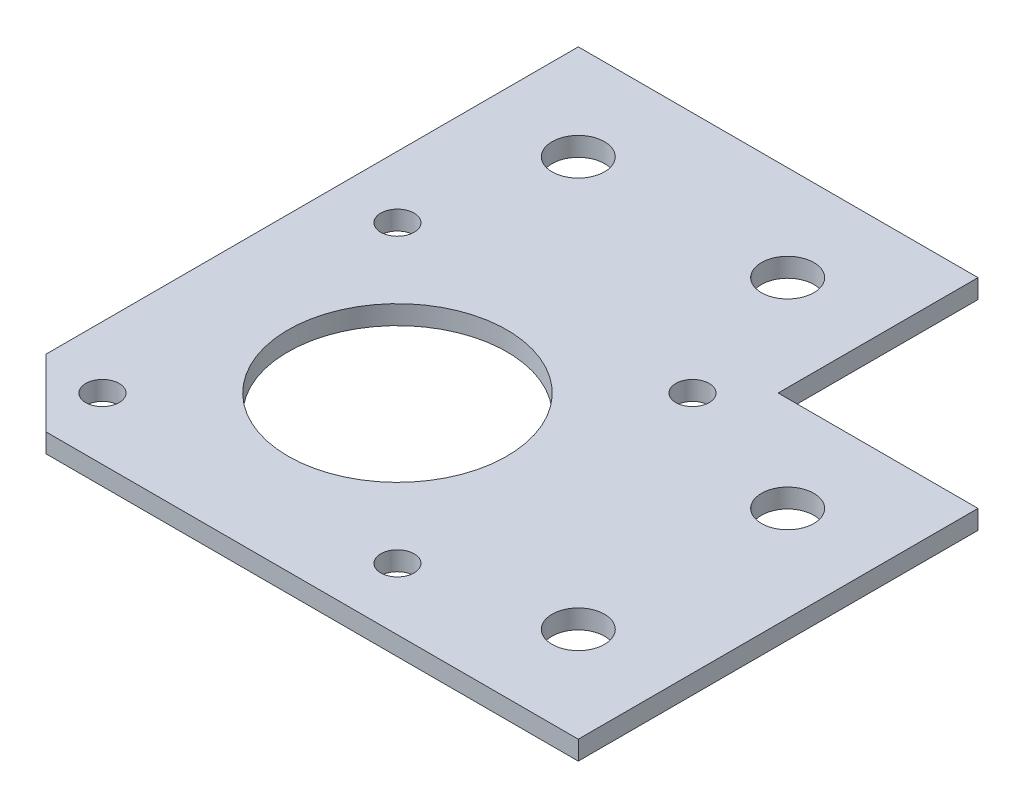
from build123d import *

# Parameters (mm, degrees)
EXTRUDE_1_DEPTH     = 2
SKETCH_3_R          = 2.75
SKETCH_3_R_2        = 1.75
SKETCH_3_R_3        = 11.5
CUT_EXTRUDE_1_DEPTH = 3


with BuildPart() as part:
    # 草图1 → 凸台-拉伸1 (new body)
    with BuildSketch(Plane(origin=(0, 0, 0), x_dir=(1, 0, 0), z_dir=(0, 1, 0))):
        Polygon((-63, 0), (-63, -63), (0, -63), (0, -21), (-21, -21), (-21, 0), align=None)
    extrude(amount=EXTRUDE_1_DEPTH)

    # 草图3 → 切除-拉伸1 (cut, through all)
    with BuildSketch(Plane(origin=(0, 2, 0), x_dir=(1, 0, 0), z_dir=(0, 1, 0))):
        with Locations((-53, -10)):
            Circle(SKETCH_3_R)
        with Locations((-56.5, -56.5)):
            Circle(SKETCH_3_R_2)
        with Locations((-25.5, -56.5)):
            Circle(SKETCH_3_R_2)
        with Locations((-25.5, -25.5)):
            Circle(SKETCH_3_R_2)
        with Locations((-56.5, -25.5)):
            Circle(SKETCH_3_R_2)
        with Locations((-41, -41)):
            Circle(SKETCH_3_R_3)
        with Locations((-10, -53)):
            Circle(SKETCH_3_R)
        with Locations((-10, -31)):
            Circle(SKETCH_3_R)
        with Locations((-31, -10)):
            Circle(SKETCH_3_R)
        Polygon((-63, -63), (-63, -55.928932188), (-55.928932188, -63), align=None)
    extrude(amount=-CUT_EXTRUDE_1_DEPTH, mode=Mode.SUBTRACT)


solid = part.part
